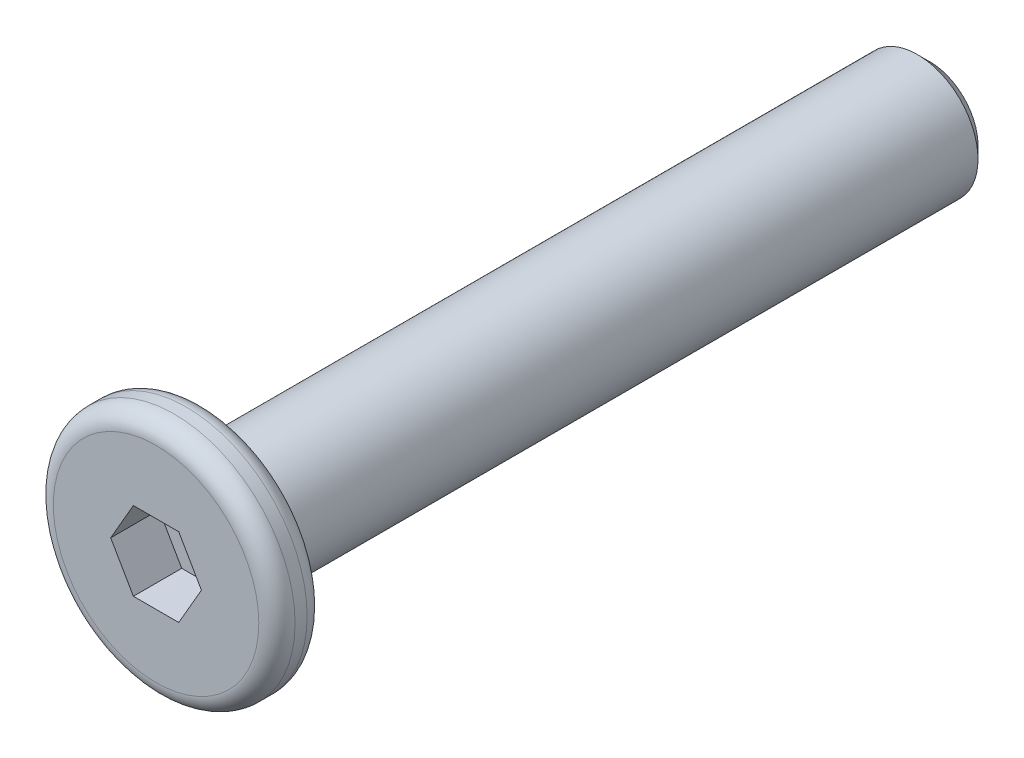
from build123d import *

# Parameters (mm, degrees)
SKETCH_1_R          = 2
EXTRUDE_1_DEPTH     = 0.4
SKETCH_2_R          = 1
EXTRUDE_2_DEPTH     = 12
CHAMFER_1_SIZE      = 0.2
CUT_EXTRUDE_1_DEPTH = 0.8
FILLET_2_R          = 0.3


with BuildPart() as part:
    # 草图1 → 凸台-拉伸1 (new body, symmetric)
    with BuildSketch(Plane.XY):
        Circle(SKETCH_1_R)
    extrude(amount=EXTRUDE_1_DEPTH, both=True)

    # 草图2 → 凸台-拉伸2 (add)
    with BuildSketch(Plane(origin=(0, 0, -0.4), x_dir=(-1, 0, 0), z_dir=(0, 0, -1))):
        Circle(SKETCH_2_R)
    extrude(amount=EXTRUDE_2_DEPTH)

    # 倒角1
    chamfer_1_edges = [part.edges().sort_by_distance(p)[0] for p in [
        (1, 0, -12.4),
    ]]
    chamfer(chamfer_1_edges, length=CHAMFER_1_SIZE)

    # 草图3 → 切除-拉伸1 (cut)
    with BuildSketch(Plane.XY.offset(0.4)):
        Polygon((0.75055535, 0), (0.375277675, 0.65), (-0.375277675, 0.65), (-0.75055535, 0), (-0.375277675, -0.65), (0.375277675, -0.65), align=None)
    extrude(amount=-CUT_EXTRUDE_1_DEPTH, mode=Mode.SUBTRACT)

    # 圆角2
    fillet_2_edges = [part.edges().sort_by_distance(p)[0] for p in [
        (-2, 0, -0.4),
        (-2, 0, 0.4),
    ]]
    fillet(fillet_2_edges, radius=FILLET_2_R)


solid = part.part
